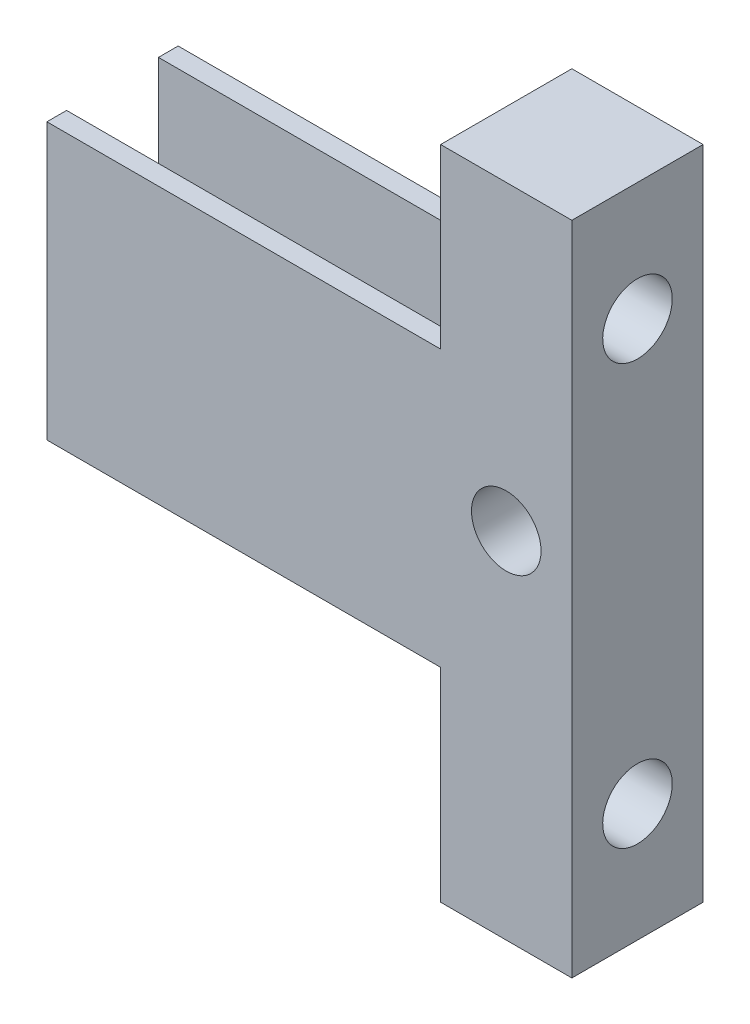
from build123d import *

# Parameters (mm, degrees)
SKETCH2_W           = 10
SKETCH2_H           = 50
BOSS_EXTRUDE1_DEPTH = 10
SKETCH6_R           = 2.65
CUT_EXTRUDE3_DEPTH  = 11
SKETCH7_R           = 2.65
CUT_EXTRUDE4_DEPTH  = 11
SKETCH8_W           = 1.5
SKETCH8_H           = 21
BOSS_EXTRUDE2_DEPTH = 30


with BuildPart() as part:
    # Sketch2 → Boss-Extrude1 (new body)
    with BuildSketch(Plane.XY):
        with Locations((5, 25)):
            Rectangle(SKETCH2_W, SKETCH2_H)
    extrude(amount=BOSS_EXTRUDE1_DEPTH)

    # Sketch6 → Cut-Extrude3 (cut, through all)
    with BuildSketch(Plane.XY.offset(10)):
        with Locations((5, 27)):
            Circle(SKETCH6_R)
    extrude(amount=-CUT_EXTRUDE3_DEPTH, mode=Mode.SUBTRACT)

    # Sketch7 → Cut-Extrude4 (cut, through all)
    with BuildSketch(Plane.ZY):
        with Locations((5, 41)):
            Circle(SKETCH7_R)
        with Locations((5, 9)):
            Circle(SKETCH7_R)
    extrude(amount=-CUT_EXTRUDE4_DEPTH, mode=Mode.SUBTRACT)

    # Sketch8 → Boss-Extrude2 (add)
    with BuildSketch(Plane.ZY):
        with Locations((9.25, 26)):
            Rectangle(SKETCH8_W, SKETCH8_H)
        with Locations((0.75, 26)):
            Rectangle(SKETCH8_W, SKETCH8_H)
    extrude(amount=BOSS_EXTRUDE2_DEPTH)


solid = part.part
